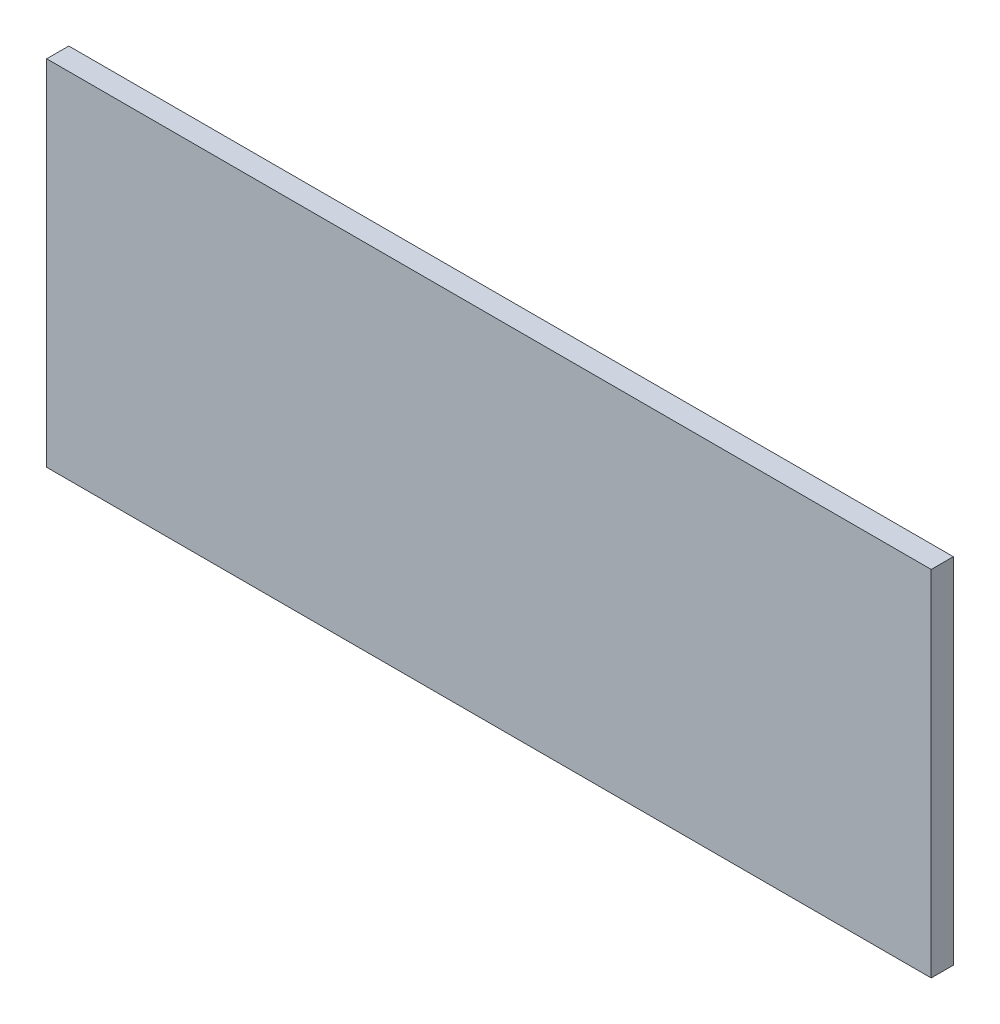
from build123d import *

# Parameters (mm, degrees)
SKETCH1_W           = 508
SKETCH1_H           = 203.2
BOSS_EXTRUDE1_DEPTH = 12.7


with BuildPart() as part:
    # Sketch1 → Boss-Extrude1 (new body)
    with BuildSketch(Plane.XY):
        Rectangle(SKETCH1_W, SKETCH1_H)
    extrude(amount=BOSS_EXTRUDE1_DEPTH)


solid = part.part
